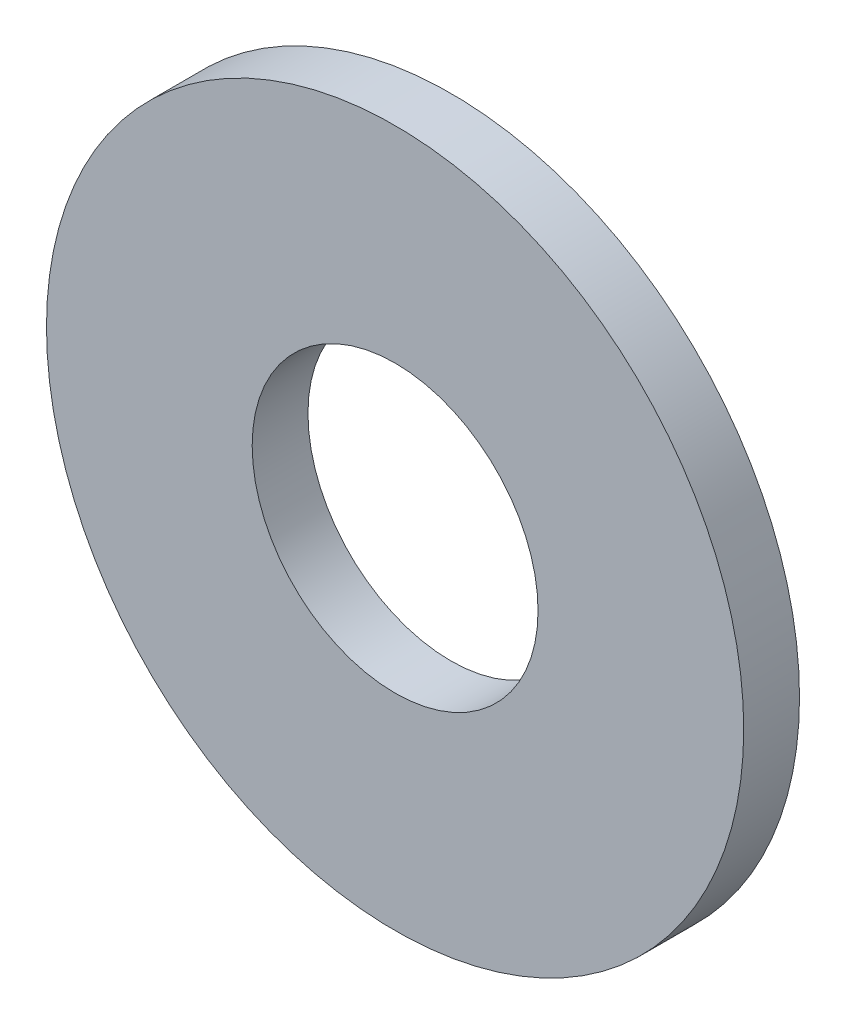
from build123d import *

# Parameters (mm, degrees)
SKETCH1_R           = 5
SKETCH1_R_2         = 2.05
BOSS_EXTRUDE1_DEPTH = 0.8


with BuildPart() as part:
    # Sketch1 → Boss-Extrude1 (new body)
    with BuildSketch(Plane.XY):
        Circle(SKETCH1_R)
        Circle(SKETCH1_R_2, mode=Mode.SUBTRACT)
    extrude(amount=BOSS_EXTRUDE1_DEPTH)


solid = part.part
